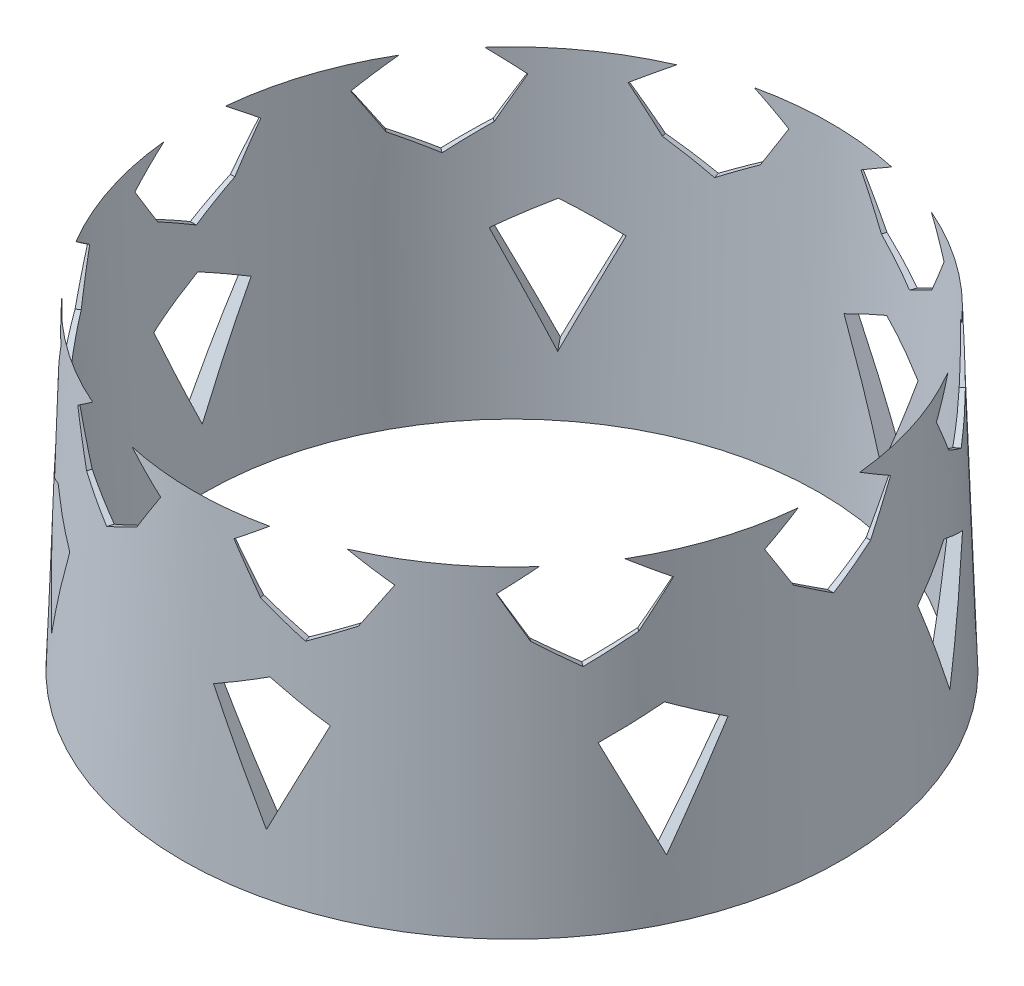
from build123d import *

# Parameters (mm, degrees)
SKETCH1_R           = 37.5
SKETCH1_R_2         = 35
BOSS_EXTRUDE1_DEPTH = 40
BOSS_EXTRUDE1_TAPER = 2
CUT_EXTRUDE1_DEPTH  = 40
CIRPATTERN1_COUNT   = 10
CUT_EXTRUDE2_DEPTH  = 40
CIRPATTERN2_COUNT   = 7
CIRPATTERN2_ANGLE   = 309


with BuildPart() as part:
    # Sketch1 → Boss-Extrude1 (new body)
    with BuildSketch(Plane(origin=(0, 0, 0), x_dir=(1, 0, 0), z_dir=(0, 1, 0))):
        Circle(SKETCH1_R)
        Circle(SKETCH1_R_2, mode=Mode.SUBTRACT)
    extrude(amount=BOSS_EXTRUDE1_DEPTH, taper=BOSS_EXTRUDE1_TAPER)

    # Sketch2 → Cut-Extrude1 (cut)
    with BuildSketch(Plane(origin=(0, 0, 0), x_dir=(0, 0, -1), z_dir=(1, 0, 0))):
        with BuildLine():
            Line((-3.5, 35.795316604), (-7.534748759, 33.202081775))
            Line((-7.534748759, 33.202081775), (-4.593988586, 28.626627084))
            Line((-4.593988586, 28.626627084), (0, 25.914355347))
            Line((0, 25.914355347), (4.219955288, 28.626627084))
            Line((4.219955288, 28.626627084), (6.92128469, 33.202081775))
            Line((6.92128469, 33.202081775), (3.5, 35.795316604))
            ThreePointArc((3.5, 35.795316604), (0, 39.295316604), (-3.5, 35.795316604))
        make_face()
    cut_extrude1 = extrude(amount=-CUT_EXTRUDE1_DEPTH, mode=Mode.SUBTRACT)

    # CirPattern1: Cut-Extrude1 ×10 about axis
    cirpattern1_axis = Axis((0, 0, 0), (0, 1, 0))
    for i in range(1, CIRPATTERN1_COUNT):
        add(cut_extrude1.rotate(cirpattern1_axis, i * 360 / CIRPATTERN1_COUNT), mode=Mode.SUBTRACT)

    # Sketch3 → Cut-Extrude2 (cut)
    with BuildSketch(Plane(origin=(0, 0, 0), x_dir=(0, 0, -1), z_dir=(1, 0, 0))):
        Polygon((0, 21.378578538), (-5.541834778, 18.44293311), (0, 6.63639335), (5.541834778, 18.44293311), align=None)
    cut_extrude2 = extrude(amount=-CUT_EXTRUDE2_DEPTH, mode=Mode.SUBTRACT)

    # CirPattern2: Cut-Extrude2 ×7 about axis
    cirpattern2_axis = Axis((0, 0, 0), (0, 1, 0))
    for i in range(1, CIRPATTERN2_COUNT):
        add(cut_extrude2.rotate(cirpattern2_axis, i * CIRPATTERN2_ANGLE / (CIRPATTERN2_COUNT - 1)), mode=Mode.SUBTRACT)


solid = part.part
